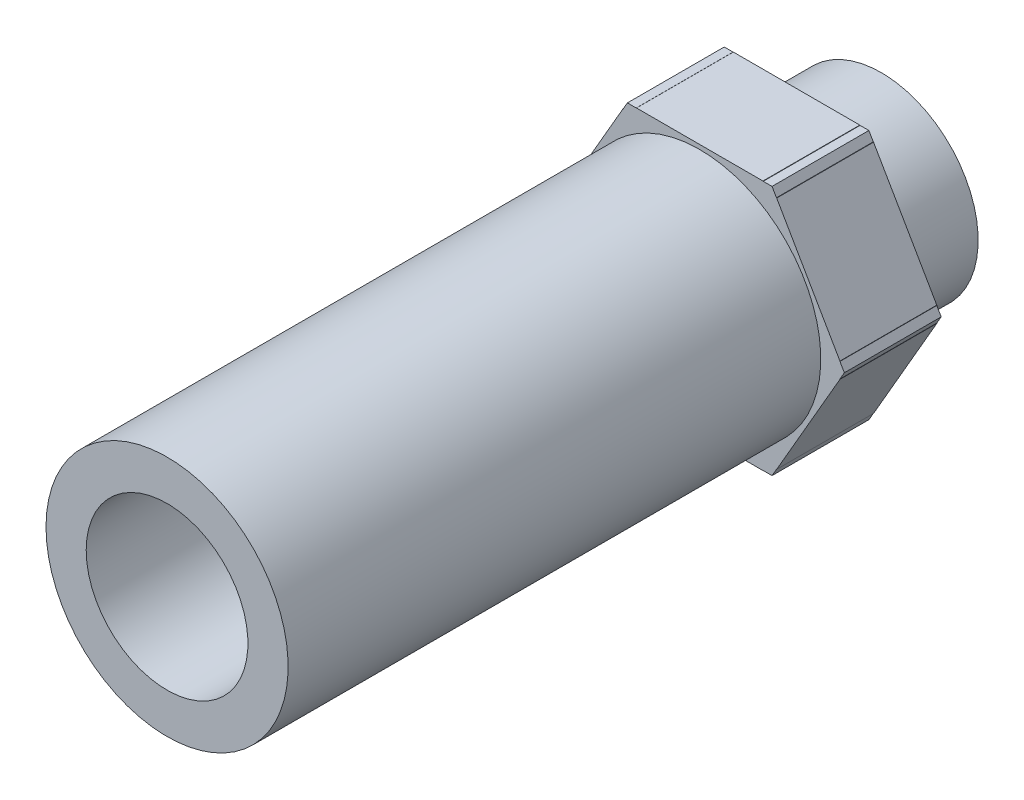
from build123d import *

# Parameters (mm, degrees)
SALIENTE_EXTRUIR1_DEPTH = 20
CROQUIS4_OUTSIDE_W      = 95.61
CROQUIS4_OUTSIDE_H      = 93.876
CORTAR_EXTRUIR3_DEPTH   = 20


with BuildPart() as part:
    # Croquis1 → Revolución1 (revolve)
    with BuildSketch(Plane(origin=(0, 0, 0), x_dir=(1, 0, 0), z_dir=(0, 1, 0))):
        Polygon((16.7, -87.44), (16.7, 17.5), (20, 17.5), (20, 0), (29, 0), (29, -20), (25, -20), (25, -130), (16.7, -130), align=None)
    revolve(axis=Axis((0, 0, -40.16), (0, 0, 1)))

    # Croquis3 → Saliente-Extruir1 (add)
    with BuildSketch(Plane.XY):
        Polygon((29.866932707, 0), (14.933466354, 25.865522458), (-14.933466354, 25.865522458), (-29.866932707, 0), (-14.933466354, -25.865522458), (14.933466354, -25.865522458), align=None)
    extrude(amount=SALIENTE_EXTRUIR1_DEPTH)

    # Croquis4 outside → Cortar-Extruir3 (cut)
    with BuildSketch(Plane.XY):
        Rectangle(CROQUIS4_OUTSIDE_W, CROQUIS4_OUTSIDE_H)
        Polygon((29.899549638, 0), (14.949774819, 25.893769548), (-14.949774819, 25.893769548), (-29.899549638, 0), (-14.949774819, -25.893769548), (14.949774819, -25.893769548), align=None, mode=Mode.SUBTRACT)
    extrude(amount=CORTAR_EXTRUIR3_DEPTH, mode=Mode.SUBTRACT)


solid = part.part
